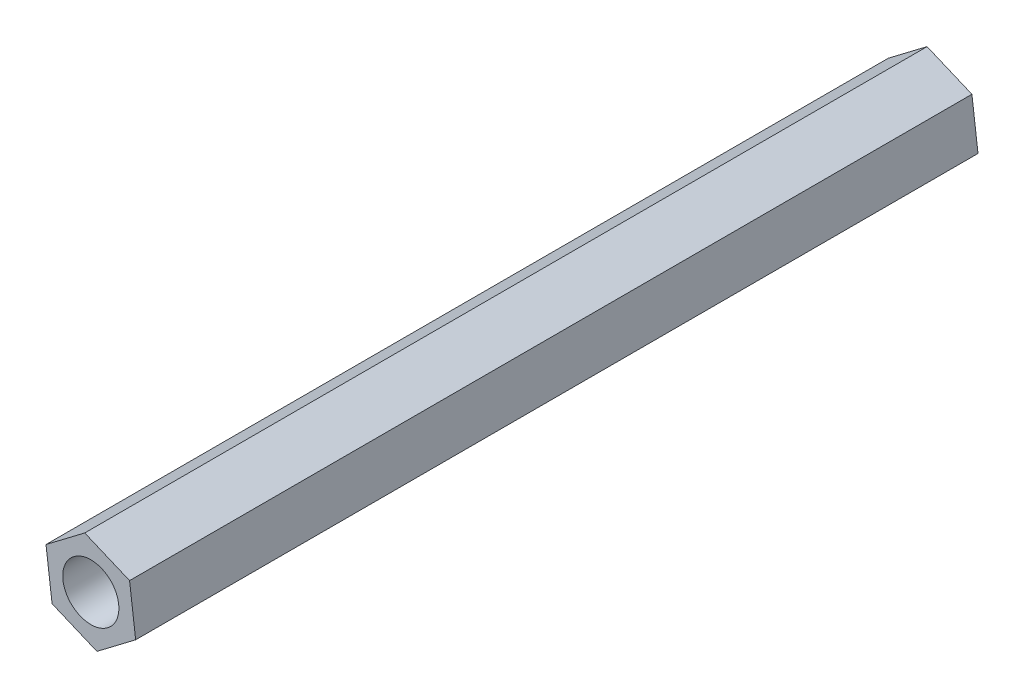
from build123d import *

# Parameters (mm, degrees)
EXTRUDE_1_DEPTH          = 60
SKETCH_2_R               = 2
CUT_EXTRUDE_1_DEPTH      = 1
CUT_EXTRUDE_1_DEPTH_BACK = 61


with BuildPart() as part:
    # 草图1 → 凸台-拉伸1 (new body)
    with BuildSketch(Plane.XY):
        Polygon((2.759819518, 2.093656186), (-0.433249685, 3.436901906), (-3.193069203, 1.34324572), (-2.759819518, -2.093656186), (0.433249685, -3.436901906), (3.193069203, -1.34324572), align=None)
    extrude(amount=EXTRUDE_1_DEPTH)

    # 草图2 → 切除-拉伸1 (cut, two sides)
    with BuildSketch(Plane.XY.offset(60)) as cut_extrude_1_sk:
        Circle(SKETCH_2_R)
    extrude(amount=CUT_EXTRUDE_1_DEPTH, mode=Mode.SUBTRACT)
    extrude(cut_extrude_1_sk.sketch, amount=-CUT_EXTRUDE_1_DEPTH_BACK, mode=Mode.SUBTRACT)


solid = part.part
